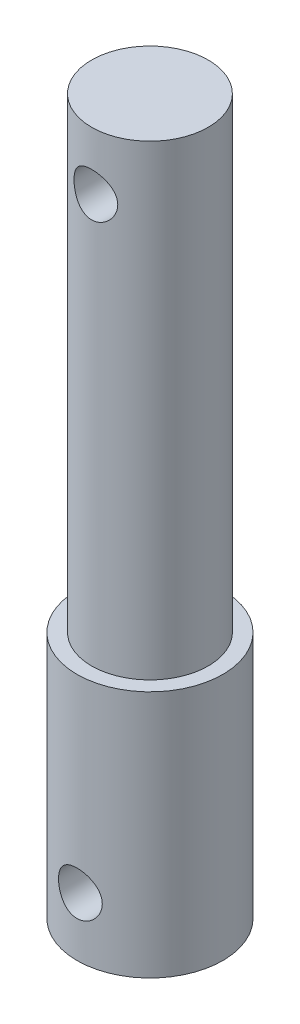
from build123d import *

# Parameters (mm, degrees)
SKETCH1_R               = 5
BOSS_EXTRUDE1_DEPTH     = 17
SKETCH1_3_R             = 4
BOSS_EXTRUDE2_DEPTH     = 49
CUT_EXTRUDE1_DEPTH      = 50.507575178
CUT_EXTRUDE1_DEPTH_BACK = 50.507575178
SKETCH2_R               = 1.5


with BuildPart() as part:
    # Sketch1 → Boss-Extrude1 (new body)
    with BuildSketch(Plane(origin=(0, 0, 0), x_dir=(1, 0, 0), z_dir=(0, 1, 0))):
        Circle(SKETCH1_R)
    extrude(amount=BOSS_EXTRUDE1_DEPTH)

    # Sketch1_3 → Boss-Extrude2 (add)
    with BuildSketch(Plane(origin=(0, 0, 0), x_dir=(1, 0, 0), z_dir=(0, 1, 0))):
        Circle(SKETCH1_3_R)
    extrude(amount=BOSS_EXTRUDE2_DEPTH)

    # Sketch2 → Cut-Extrude1 (cut, two sides: drawn at the far end of the back side and taken through both)
    with BuildSketch(Plane.XY.offset(-CUT_EXTRUDE1_DEPTH_BACK)):
        with Locations((0, 45)):
            Circle(SKETCH2_R)
        with Locations((0, 4)):
            Circle(SKETCH2_R)
    extrude(amount=CUT_EXTRUDE1_DEPTH + CUT_EXTRUDE1_DEPTH_BACK, mode=Mode.SUBTRACT)


solid = part.part
